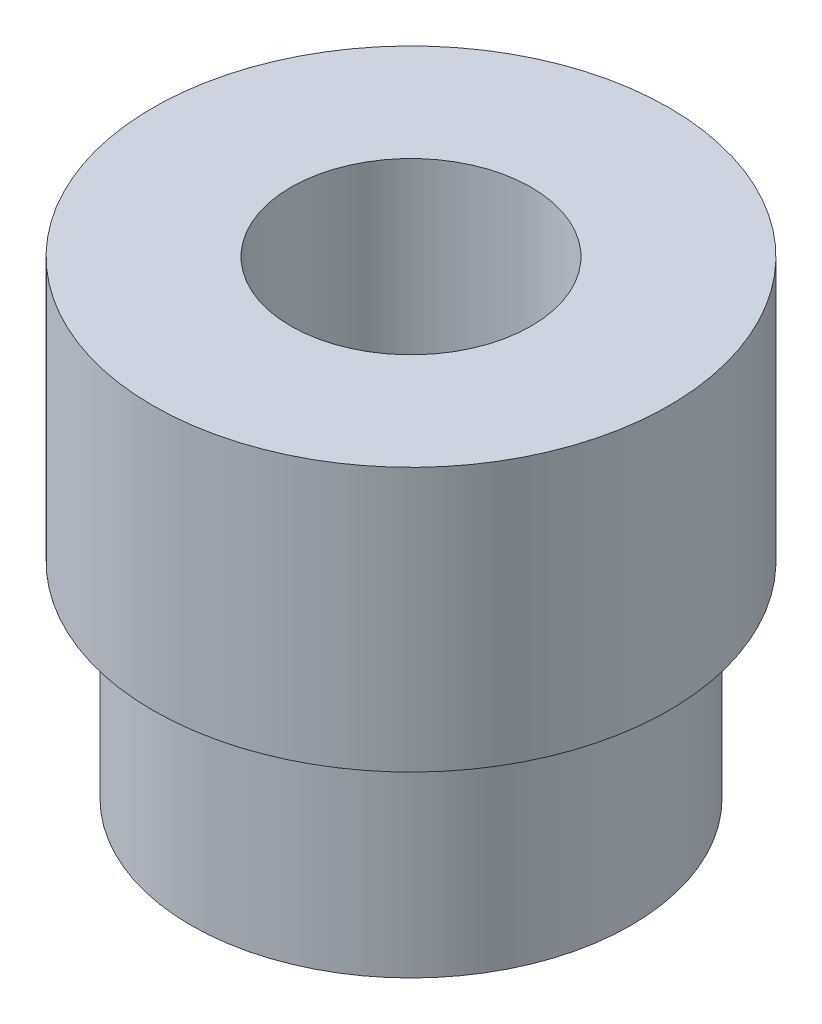
from build123d import *

# Parameters (mm, degrees)
SKETCH1_R           = 7.3
SKETCH1_R_2         = 2.4
BOSS_EXTRUDE1_DEPTH = 10
SKETCH2_R           = 8.8
SKETCH2_R_2         = 7.3
BOSS_EXTRUDE2_DEPTH = 3
SKETCH3_R           = 8.8
SKETCH3_R_2         = 2.4
BOSS_EXTRUDE3_DEPTH = 6
SKETCH4_R           = 4.2
SKETCH4_R_2         = 2.4
CUT_EXTRUDE1_DEPTH  = 43
BOSS_EXTRUDE4_REACH = 18
SKETCH5_R           = 7.5
SKETCH5_R_2         = 7.3
SKETCH6_R           = 4.2
SKETCH6_R_2         = 4.1
BOSS_EXTRUDE5_DEPTH = 16


with BuildPart() as part:
    # Sketch1 → Boss-Extrude1 (new body)
    with BuildSketch(Plane(origin=(0, 0, 0), x_dir=(1, 0, 0), z_dir=(0, 1, 0))):
        Circle(SKETCH1_R)
        Circle(SKETCH1_R_2, mode=Mode.SUBTRACT)
    extrude(amount=BOSS_EXTRUDE1_DEPTH)

    # Sketch2 → Boss-Extrude2 (add)
    with BuildSketch(Plane(origin=(0, 10, 0), x_dir=(1, 0, 0), z_dir=(0, 1, 0))):
        Circle(SKETCH2_R)
        Circle(SKETCH2_R_2, mode=Mode.SUBTRACT)
    extrude(amount=-BOSS_EXTRUDE2_DEPTH)

    # Sketch3 → Boss-Extrude3 (add)
    with BuildSketch(Plane(origin=(0, 10, 0), x_dir=(1, 0, 0), z_dir=(0, 1, 0))):
        Circle(SKETCH3_R)
        Circle(SKETCH3_R_2, mode=Mode.SUBTRACT)
    extrude(amount=BOSS_EXTRUDE3_DEPTH)

    # Sketch4 → Cut-Extrude1 (cut)
    with BuildSketch(Plane(origin=(0, 16, 0), x_dir=(1, 0, 0), z_dir=(0, 1, 0))):
        Circle(SKETCH4_R)
        Circle(SKETCH4_R_2, mode=Mode.SUBTRACT)
    extrude(amount=-CUT_EXTRUDE1_DEPTH, mode=Mode.SUBTRACT)

    # Sketch5 → Boss-Extrude4 (add, up to next)
    with BuildSketch(Plane.XZ, mode=Mode.PRIVATE) as boss_extrude4_sk1:
        Circle(SKETCH5_R)
        Circle(SKETCH5_R_2, mode=Mode.SUBTRACT)
    boss_extrude4_tool1 = extrude(boss_extrude4_sk1.sketch, amount=-BOSS_EXTRUDE4_REACH, mode=Mode.PRIVATE) - part.part
    add(boss_extrude4_tool1.solids().sort_by_distance((-7.478787, 0, 0))[0])

    # Sketch6 → Boss-Extrude5 (add)
    with BuildSketch(Plane.XZ):
        Circle(SKETCH6_R)
        Circle(SKETCH6_R_2, mode=Mode.SUBTRACT)
    extrude(amount=-BOSS_EXTRUDE5_DEPTH)


solid = part.part
